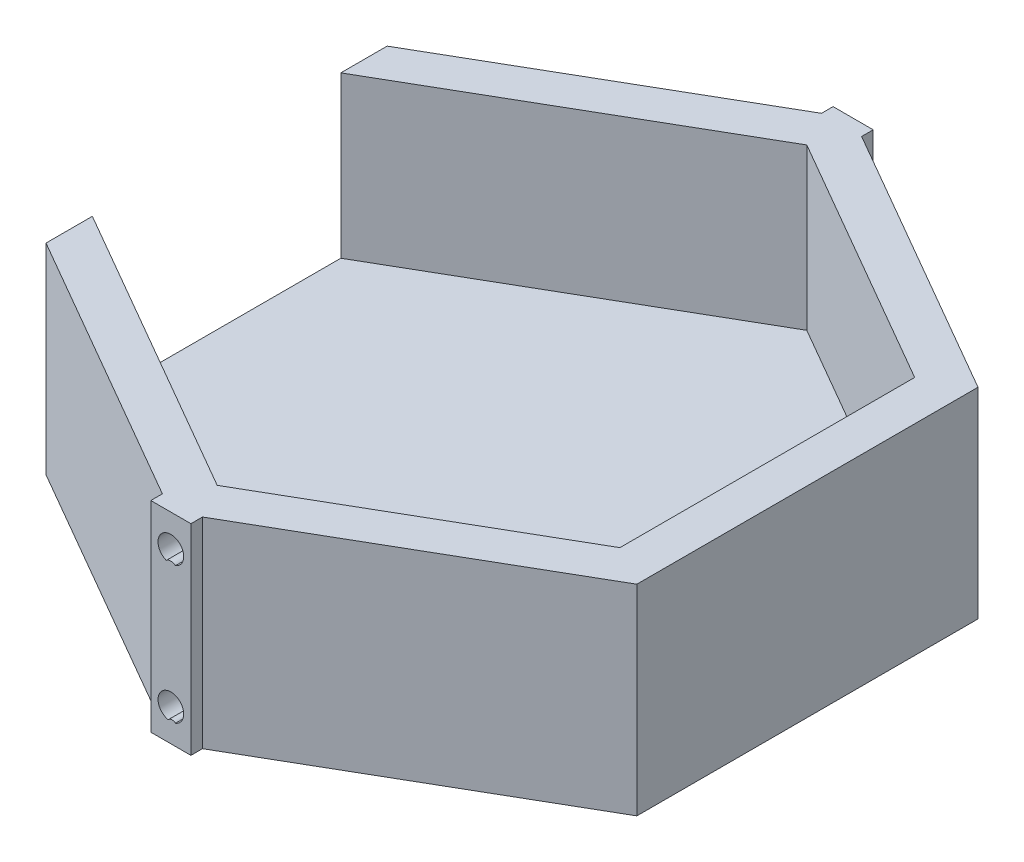
from build123d import *

# Parameters (mm, degrees)
BOSS_EXTRUDE1_DEPTH = 25
SHELL1_T            = -5
SKETCH3_W           = 5
SKETCH3_H           = 25
BOSS_EXTRUDE3_DEPTH = 5
CUT_EXTRUDE1_DEPTH  = 4.5


with BuildPart() as part:
    # Sketch1 → Boss-Extrude1 (new body)
    with BuildSketch(Plane(origin=(0, 0, 0), x_dir=(1, 0, 0), z_dir=(0, 1, 0))):
        Polygon((0, 42.5), (-36.806079661, 21.25), (-36.806079661, -21.25), (0, -42.5), (36.806079661, -21.25), (36.806079661, 21.25), align=None)
    extrude(amount=BOSS_EXTRUDE1_DEPTH)

    # Shell1
    shell1_openings = [part.faces().sort_by_distance(p)[0] for p in [
        (0, 25, 0),
        (-36.806079661, 12.5, 0),
    ]]
    offset(amount=SHELL1_T, openings=shell1_openings, kind=Kind.INTERSECTION)

    # Sketch3 → Boss-Extrude3 (add)
    with BuildSketch(Plane.XY.offset(-42.5)):
        with Locations((0, 12.5)):
            Rectangle(SKETCH3_W, SKETCH3_H)
    boss_extrude3 = extrude(amount=BOSS_EXTRUDE3_DEPTH)

    # Sketch4 → Cut-Extrude1 (cut)
    with BuildSketch(Plane(origin=(0, 0, -42.5), x_dir=(-1, 0, 0), z_dir=(0, 0, -1))):
        with BuildLine():
            ThreePointArc((0.573600046, 19.506352456), (1.318666007, 20.093843301), (1.6, 21))
            ThreePointArc((1.6, 21), (-0.906156699, 22.318666007), (-0.573600046, 19.506352456))
            ThreePointArc((-0.573600046, 19.506352456), (0, 19.71460041), (0.573600046, 19.506352456))
        make_face()
        with BuildLine():
            ThreePointArc((0.329089607, 2.434209455), (1.242284865, 2.991670533), (1.6, 4))
            ThreePointArc((1.6, 4), (-0.906156699, 5.318666007), (-0.573600046, 2.506352456))
            ThreePointArc((-0.573600046, 2.506352456), (-0.107313915, 2.657234104), (0.329089607, 2.434209455))
        make_face()
    cut_extrude1 = extrude(amount=-CUT_EXTRUDE1_DEPTH, mode=Mode.SUBTRACT)

    # Mirror1: Boss-Extrude3, Cut-Extrude1 across plane
    add(boss_extrude3.mirror(Plane.XY))
    add(cut_extrude1.mirror(Plane.XY), mode=Mode.SUBTRACT)


solid = part.part
